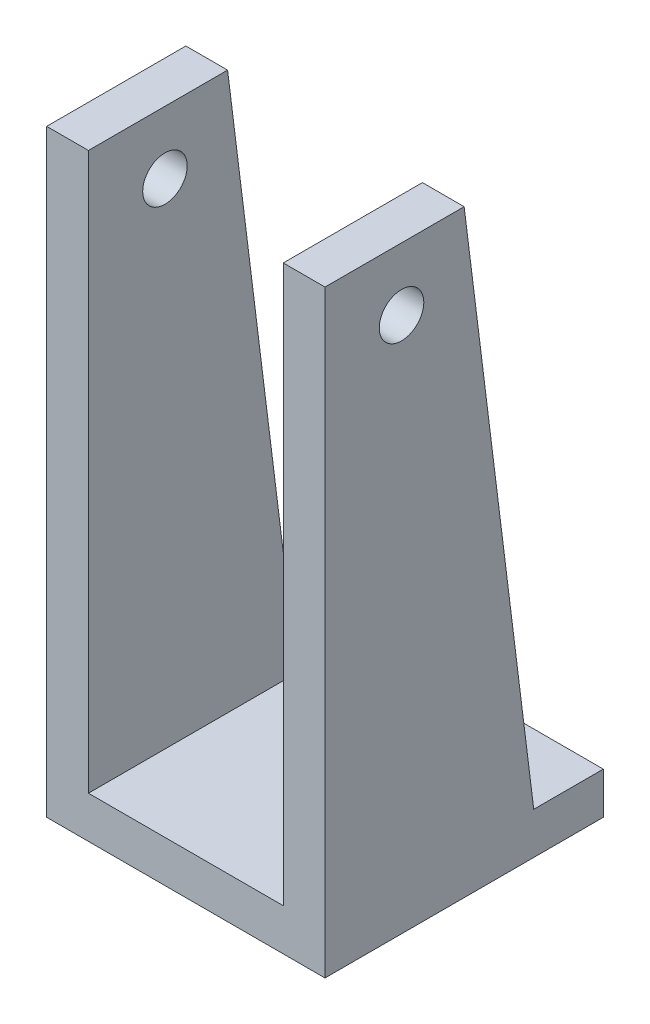
from build123d import *

# Parameters (mm, degrees)
SKETCH_1_W          = 20
SKETCH_1_H          = 20
EXTRUDE_1_DEPTH     = 3
EXTRUDE_2_DEPTH     = 3
EXTRUDE_3_DEPTH     = 3
SKETCH_6_R          = 1.6
CUT_EXTRUDE_1_DEPTH = 21
SKETCH_8_R          = 2
CUT_EXTRUDE_2_DEPTH = 4


with BuildPart() as part:
    # 草图1 → 凸台-拉伸1 (new body)
    with BuildSketch(Plane(origin=(0, 0, 0), x_dir=(1, 0, 0), z_dir=(0, 1, 0))):
        Rectangle(SKETCH_1_W, SKETCH_1_H)
    extrude(amount=EXTRUDE_1_DEPTH)

    # 草图4 → 凸台-拉伸2 (add)
    with BuildSketch(Plane.ZY.offset(10)):
        Polygon((10, 3), (10, 43), (0, 43), (-5, 3), align=None)
    extrude(amount=-EXTRUDE_2_DEPTH)

    # 草图5 → 凸台-拉伸3 (add)
    with BuildSketch(Plane(origin=(10, 0, 0), x_dir=(0, 0, -1), z_dir=(1, 0, 0))):
        Polygon((-10, 3), (5, 3), (0, 43), (-10, 43), align=None)
    extrude(amount=-EXTRUDE_3_DEPTH)

    # 草图6 → 切除-拉伸1 (cut, through all)
    with BuildSketch(Plane(origin=(10, 0, 0), x_dir=(0, 0, -1), z_dir=(1, 0, 0))):
        with Locations((-4.5, 38.5)):
            Circle(SKETCH_6_R)
    extrude(amount=-CUT_EXTRUDE_1_DEPTH, mode=Mode.SUBTRACT)

    # 草图8 → 切除-拉伸2 (cut, through all)
    with BuildSketch(Plane(origin=(0, 3, 0), x_dir=(1, 0, 0), z_dir=(0, 1, 0))):
        Circle(SKETCH_8_R)
    extrude(amount=-CUT_EXTRUDE_2_DEPTH, mode=Mode.SUBTRACT)


solid = part.part
